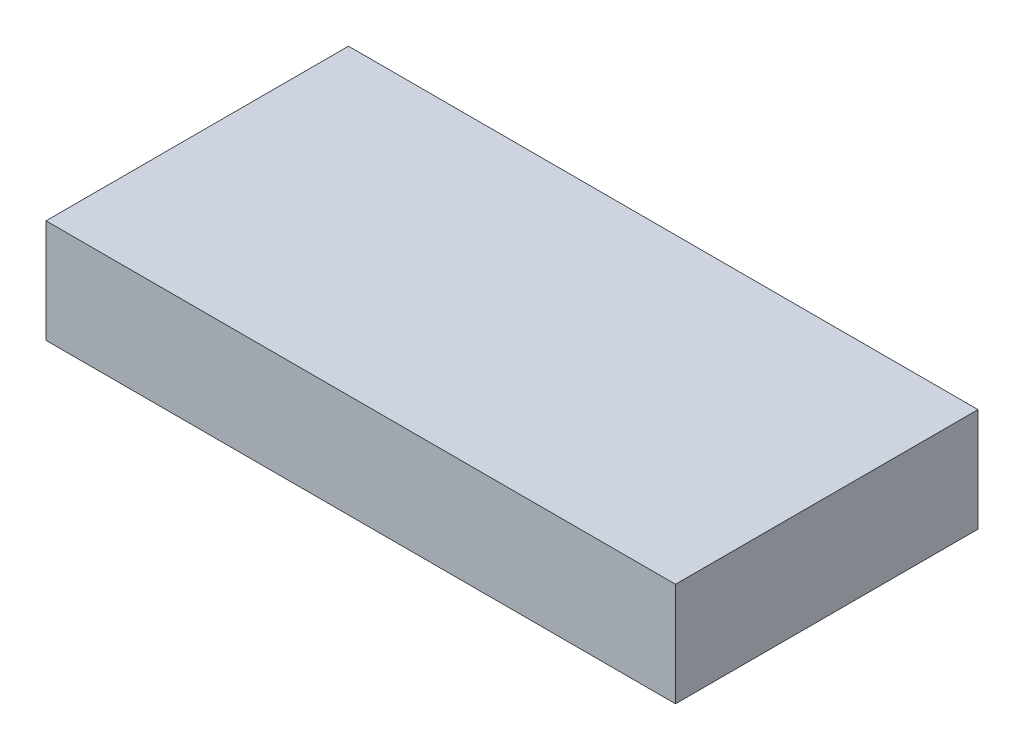
from build123d import *

# Parameters (mm, degrees)
SKETCH1_W           = 366.7125
SKETCH1_H           = 176.2125
BOSS_EXTRUDE1_DEPTH = 60.325


with BuildPart() as part:
    # Sketch1 → Boss-Extrude1 (new body)
    with BuildSketch(Plane(origin=(0, 0, 0), x_dir=(1, 0, 0), z_dir=(0, 1, 0))):
        Rectangle(SKETCH1_W, SKETCH1_H)
    extrude(amount=BOSS_EXTRUDE1_DEPTH)


solid = part.part
